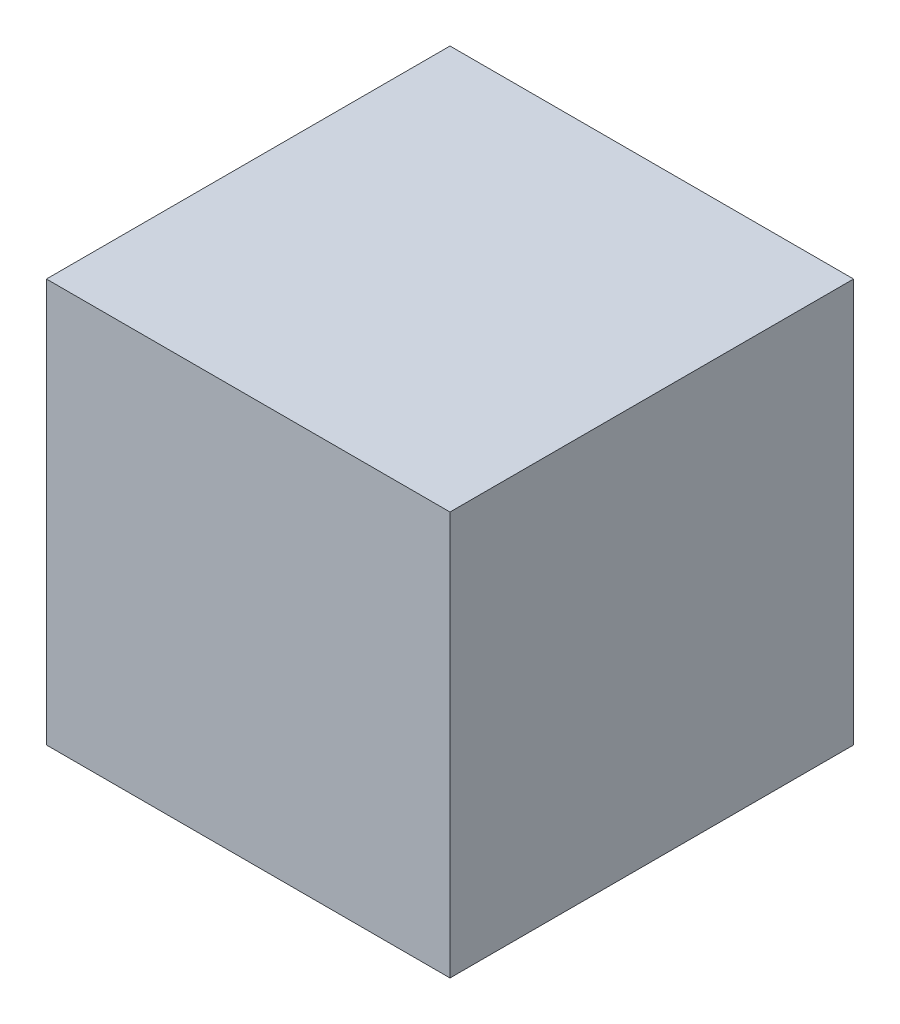
from build123d import *

# Parameters (mm, degrees)
SKETCH1_W           = 1219.2
SKETCH1_H           = 1219.2
BOSS_EXTRUDE1_DEPTH = 1219.2


with BuildPart() as part:
    # Sketch1 → Boss-Extrude1 (new body)
    with BuildSketch(Plane(origin=(0, 0, 0), x_dir=(1, 0, 0), z_dir=(0, 1, 0))):
        with Locations((565.8232827, 562.895074185)):
            Rectangle(SKETCH1_W, SKETCH1_H)
    extrude(amount=BOSS_EXTRUDE1_DEPTH)


solid = part.part
